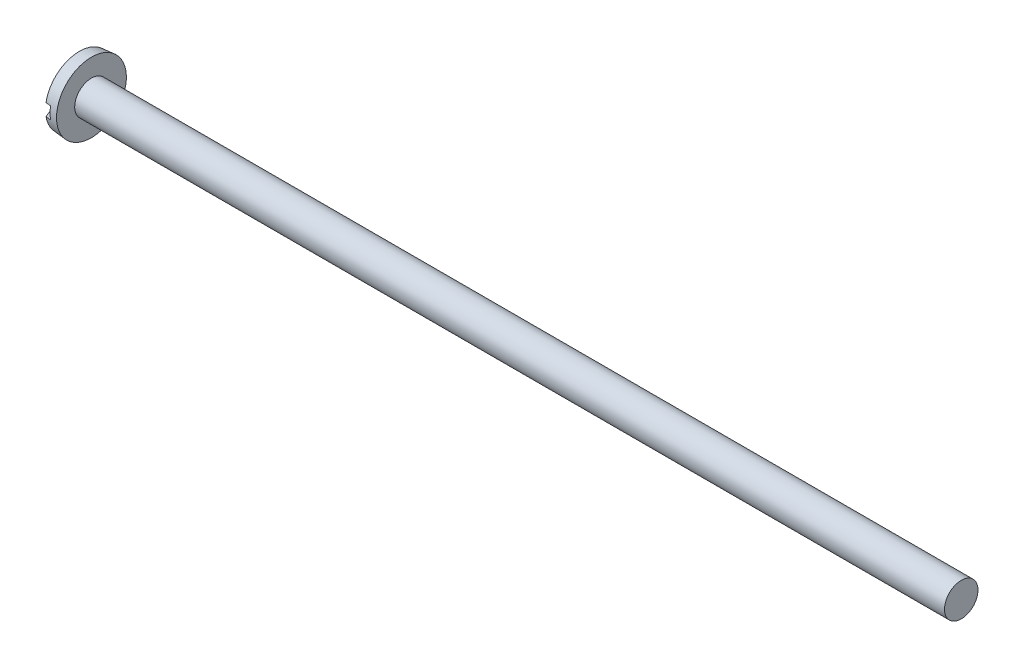
from build123d import *

# Parameters (mm, degrees)
SKETCH2_W                    = 2.4892
SKETCH2_H                    = 0.4318
SLOT_DEPTH                   = 0.4572
SCHIZZO2_R                   = 0.5969
ESTRUSIONE_ESTRUSIONE1_DEPTH = 15.1257


with BuildPart() as part:
    # BodySke → Base-Revolve (revolve)
    with BuildSketch(Plane.XY):
        with BuildLine():
            Line((0.7112, 0.5969), (0.7112, 1.2446))
            Line((0.7112, 1.2446), (0.2794, 1.206822395))
            ThreePointArc((0.2794, 1.206822395), (0.070761718, 0.619371587), (0, 0))
            Line((0, 0), (16.5862, 0))
            Line((16.5862, 0), (16.5862, 0.5969))
            Line((16.5862, 0.5969), (0.7112, 0.5969))
        make_face()
    revolve(axis=Axis((-25.4, 0, 0), (1, 0, 0)))

    # Sketch2 → Slot (cut)
    with BuildSketch(Plane(origin=(0, 0, 0), x_dir=(0, 0, -1), z_dir=(1, 0, 0))):
        Rectangle(SKETCH2_W, SKETCH2_H)
    extrude(amount=SLOT_DEPTH, mode=Mode.SUBTRACT)

    # Schizzo2 → Estrusione-Estrusione1 (add)
    with BuildSketch(Plane(origin=(16.5862, 0, 0), x_dir=(0, 0, -1), z_dir=(1, 0, 0))):
        Circle(SCHIZZO2_R)
    extrude(amount=ESTRUSIONE_ESTRUSIONE1_DEPTH)


solid = part.part
